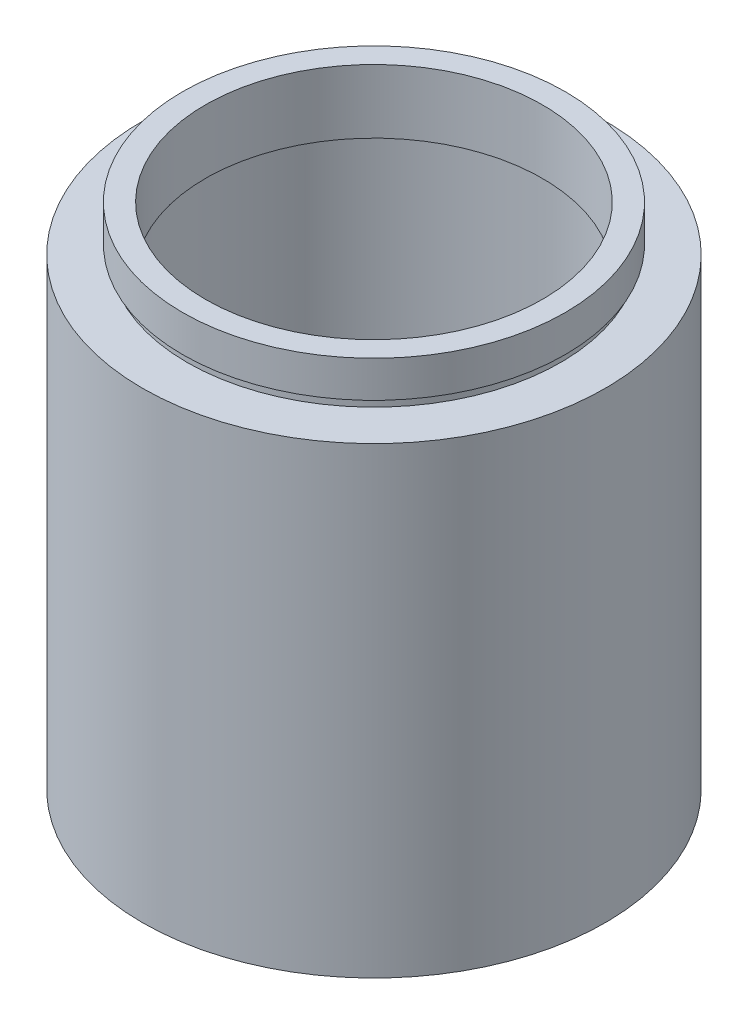
from build123d import *


with BuildPart() as part:
    # 草图1 → 旋转1 (revolve)
    with BuildSketch(Plane.XY, mode=Mode.PRIVATE) as revolve_1_sk:
        Polygon((18.5, 55.8), (21, 55.8), (21, 51.8), (20.5, 51.8), (20.5, 50.8), (25.4, 50.8), (25.4, 0), (20.5, 0), (20.5, 47.8), (21.1, 47.8), (21.1, 48.8), (18.5, 48.8), align=None)
    revolve(revolve_1_sk.sketch.rotate(Axis((0, 161.376166943, 0), (0, -1, 0)), 90), axis=Axis((0, 161.376166943, 0), (0, -1, 0)))  # turned: the seam where the file's is


solid = part.part
